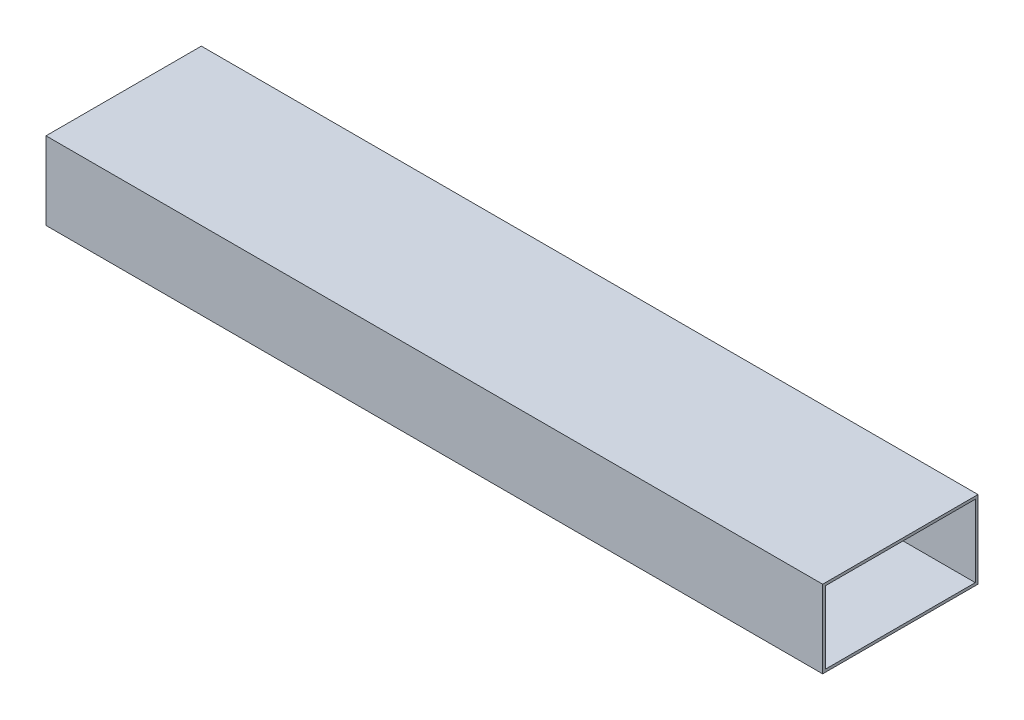
from build123d import *

# Parameters (mm, degrees)
SKETCH1_W           = 50.8
SKETCH1_H           = 25.4
SKETCH1_W_2         = 49.022
SKETCH1_H_2         = 23.622
BOSS_EXTRUDE1_DEPTH = 127


with BuildPart() as part:
    # Sketch1 → Boss-Extrude1 (new, symmetric)
    with BuildSketch(Plane(origin=(0, 0, 0), x_dir=(0, 0, -1), z_dir=(1, 0, 0))):
        Rectangle(SKETCH1_W, SKETCH1_H)
        Rectangle(SKETCH1_W_2, SKETCH1_H_2, mode=Mode.SUBTRACT)
    extrude(amount=BOSS_EXTRUDE1_DEPTH, both=True)


solid = part.part
